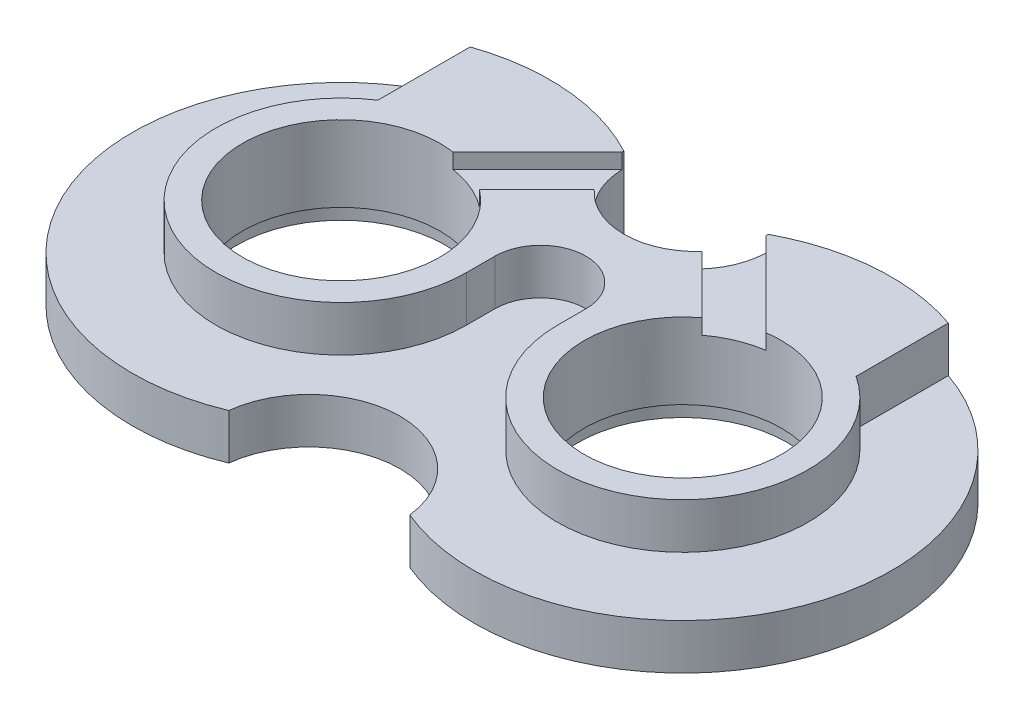
from build123d import *

# Parameters (mm, degrees)
EXTRUDE_1_DEPTH     = 12
SKETCH_2_R          = 9.5
SKETCH_2_R_2        = 12
CUT_EXTRUDE_1_DEPTH = 13
CUT_EXTRUDE_2_DEPTH = 6
SKETCH_4_R          = 13
CUT_EXTRUDE_3_DEPTH = 13
SKETCH_7_R          = 13.75
CUT_EXTRUDE_5_DEPTH = 2
CUT_EXTRUDE_6_DEPTH = 2


with BuildPart() as part:
    # Эскиз1 → Бобышка-Вытянуть1 (new body)
    with BuildSketch(Plane(origin=(0, 0, 0), x_dir=(1, 0, 0), z_dir=(0, 1, 0))):
        with BuildLine():
            ThreePointArc((0, -15.811388301), (50, 0), (0, 15.811388301))
            ThreePointArc((0, 15.811388301), (-50, 0), (0, -15.811388301))
        make_face()
    extrude(amount=EXTRUDE_1_DEPTH)

    # Эскиз2 → Вырез-Вытянуть1 (cut, through all)
    with BuildSketch(Plane(origin=(0, 0, 0), x_dir=(1, 0, 0), z_dir=(0, 1, 0))):
        with Locations((0, 24.25)):
            Circle(SKETCH_2_R)
        with Locations((0, -26.75)):
            Circle(SKETCH_2_R_2)
    extrude(amount=CUT_EXTRUDE_1_DEPTH, mode=Mode.SUBTRACT)

    # Эскиз3 → Вырез-Вытянуть2 (cut)
    with BuildSketch(Plane(origin=(0, 12, 0), x_dir=(1, 0, 0), z_dir=(0, 1, 0))):
        with BuildLine():
            Line((-6, 0), (-6, 3.75))
            ThreePointArc((-6, 3.75), (0, 9.75), (6, 3.75))
            Line((6, 3.75), (6, 0))
            ThreePointArc((6, 0), (30.366066361, -14.504309704), (31.5, 13.829316686))
            Line((31.5, 13.829316686), (31.5, 40))
            Line((31.5, 40), (71.5, 40))
            Line((71.5, 40), (71.5, -30))
            Line((71.5, -30), (-71.5, -30))
            Line((-71.5, -30), (-71.5, 40))
            Line((-71.5, 40), (-31.5, 40))
            Line((-31.5, 40), (-31.5, 13.829316686))
            ThreePointArc((-31.5, 13.829316686), (-30.366066361, -14.504309704), (-6, 0))
        make_face()
    extrude(amount=-CUT_EXTRUDE_2_DEPTH, mode=Mode.SUBTRACT)

    # Эскиз4 → Вырез-Вытянуть3 (cut, through all)
    with BuildSketch(Plane(origin=(0, 0, 0), x_dir=(1, 0, 0), z_dir=(0, 1, 0))):
        with Locations((-22.5, 0)):
            Circle(SKETCH_4_R)
        with Locations((22.5, 0)):
            Circle(SKETCH_4_R)
    extrude(amount=CUT_EXTRUDE_3_DEPTH, mode=Mode.SUBTRACT)

    # Эскиз7 → Вырез-Вытянуть5 (cut)
    with BuildSketch(Plane.XZ):
        with Locations((-22.5, 0)):
            Circle(SKETCH_7_R)
        with Locations((22.5, 0)):
            Circle(SKETCH_7_R)
    extrude(amount=-CUT_EXTRUDE_5_DEPTH, mode=Mode.SUBTRACT)

    # Эскиз8 → Вырез-Вытянуть6 (cut)
    with BuildSketch(Plane(origin=(0, 12, 0), x_dir=(1, 0, 0), z_dir=(0, 1, 0))):
        Polygon((-9.242640687, 24.242640687), (-26.920310217, 6.564971157), (-22.67766953, 2.32233047), (-5, 20), align=None)
        Polygon((9.242640687, 24.242640687), (26.920310217, 6.564971157), (22.67766953, 2.32233047), (5, 20), align=None)
    extrude(amount=-CUT_EXTRUDE_6_DEPTH, mode=Mode.SUBTRACT)


solid = part.part
